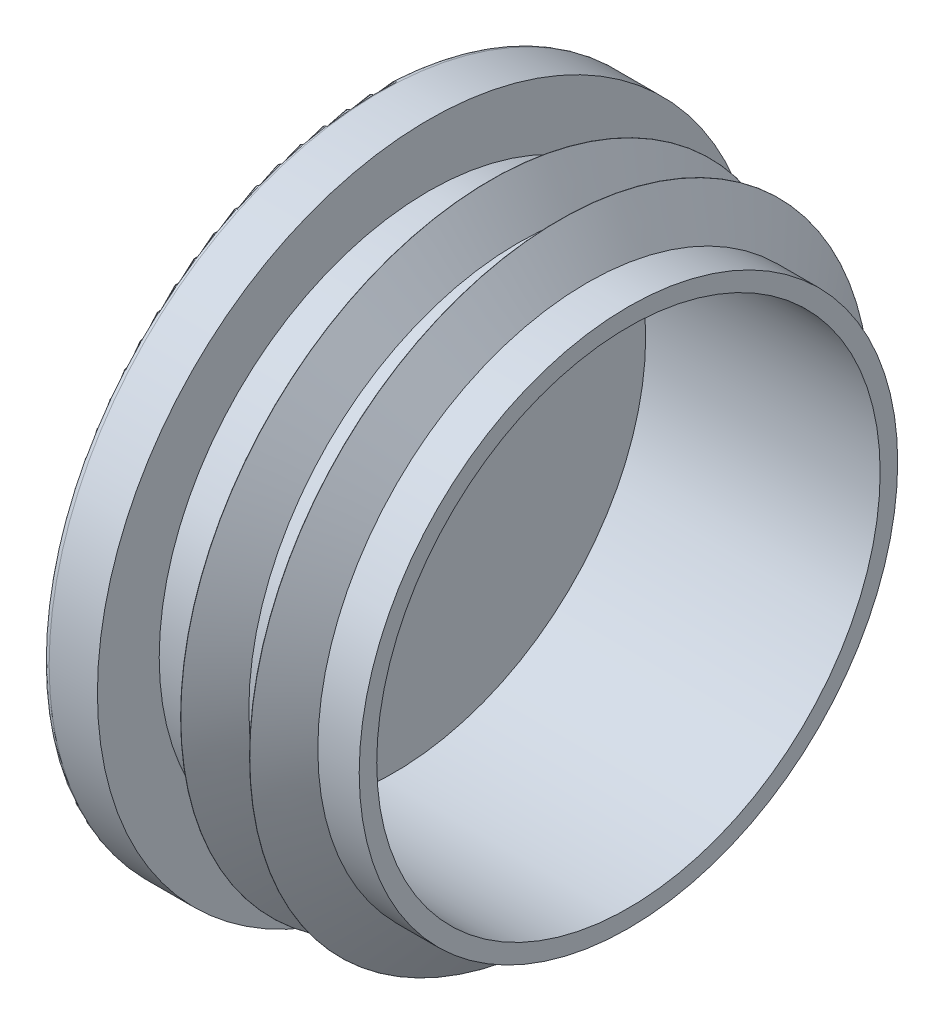
from build123d import *

# Parameters (mm, degrees)
FILLET1_R = 0.01
FILLET2_R = 0.5


with BuildPart() as part:
    # Sketch1 → Revolve1 (revolve)
    with BuildSketch(Plane.XY):
        Polygon((0, 24), (0, 0), (1.5, 0), (1.5, 18.25), (18.5, 18.25), (18.5, 19.521176082), (15.5, 19.521176082), (13.5, 22.5), (13.5, 19.521176082), (10.5, 19.521176082), (8.5, 22.5), (8.5, 19.521176082), (4, 19.521176082), (4, 24), align=None)
    revolve(axis=Axis((0, 0, 0), (1, 0, 0)))

    # Fillet1
    fillet1_edges = [part.edges().sort_by_distance(p)[0] for p in [
        (8.5, -22.5, 0),
        (13.5, -22.5, 0),
    ]]
    fillet(fillet1_edges, radius=FILLET1_R)

    # Fillet2
    fillet2_edges = [part.edges().sort_by_distance(p)[0] for p in [
        (0, -24, 0),
    ]]
    fillet(fillet2_edges, radius=FILLET2_R)


solid = part.part
